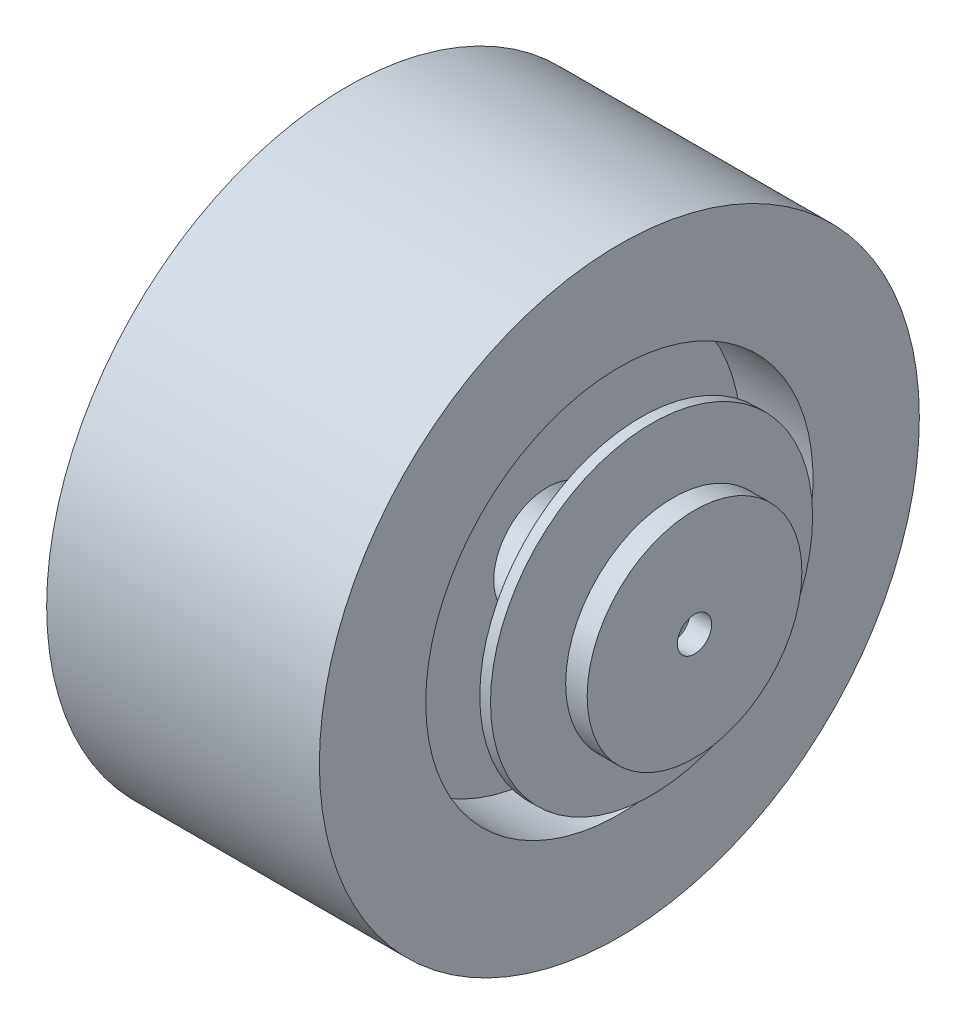
from build123d import *

# Parameters (mm, degrees)
BOSS_EXTRUDE1_START = 10
SKETCH2_R           = 75
BOSS_EXTRUDE1_DEPTH = 5
BOSS_EXTRUDE2_START = 10
SKETCH3_R           = 50
BOSS_EXTRUDE2_DEPTH = 10
SKETCH4_R           = 8
CUT_EXTRUDE1_DEPTH  = 163


with BuildPart() as part:
    # Sketch1 → Revolve1 (revolve)
    with BuildSketch(Plane.XY):
        Polygon((0, -25), (0, -139.7), (-63.5, -139.7), (-63.5, -90.17), (-30, -90.17), (-30, -25), align=None)
    revolve1 = revolve(axis=Axis((-62.857142857, 0, 0), (1, 0, 0)))

    # Mirror1: Revolve1 across plane
    add(revolve1.mirror(Plane(origin=(0, 0, 0), x_dir=(0, 0, 1), z_dir=(1, 0, 0))))


with BuildPart() as body_2:
    # Sketch2 → Boss-Extrude1 (new body)
    with BuildSketch(Plane(origin=(63.5, 0, 0), x_dir=(0, 0, -1), z_dir=(1, 0, 0)).offset(BOSS_EXTRUDE1_START)):
        Circle(SKETCH2_R)
    extrude(amount=BOSS_EXTRUDE1_DEPTH)


with BuildPart() as body_3:
    # Sketch3 → Boss-Extrude2 (new body)
    with BuildSketch(Plane(origin=(78.5, 0, 0), x_dir=(0, 0, -1), z_dir=(1, 0, 0)).offset(BOSS_EXTRUDE2_START)):
        Circle(SKETCH3_R)
    extrude(amount=BOSS_EXTRUDE2_DEPTH)


with BuildPart() as cut_extrude1_tool:
    # Sketch4 → Cut-Extrude1 (new body, through all)
    with BuildSketch(Plane(origin=(98.5, 0, 0), x_dir=(0, 0, -1), z_dir=(1, 0, 0))):
        Circle(SKETCH4_R)
    extrude(amount=-CUT_EXTRUDE1_DEPTH)


with BuildPart() as body_2_1:
    add(body_2.part)

    # Cut-Extrude1: cut by cut_extrude1_tool
    add(cut_extrude1_tool.part, mode=Mode.SUBTRACT)


with BuildPart() as body_3_1:
    add(body_3.part)

    # Cut-Extrude1: cut by cut_extrude1_tool
    add(cut_extrude1_tool.part, mode=Mode.SUBTRACT)


solid = Compound([part.part, body_2_1.part, body_3_1.part])
